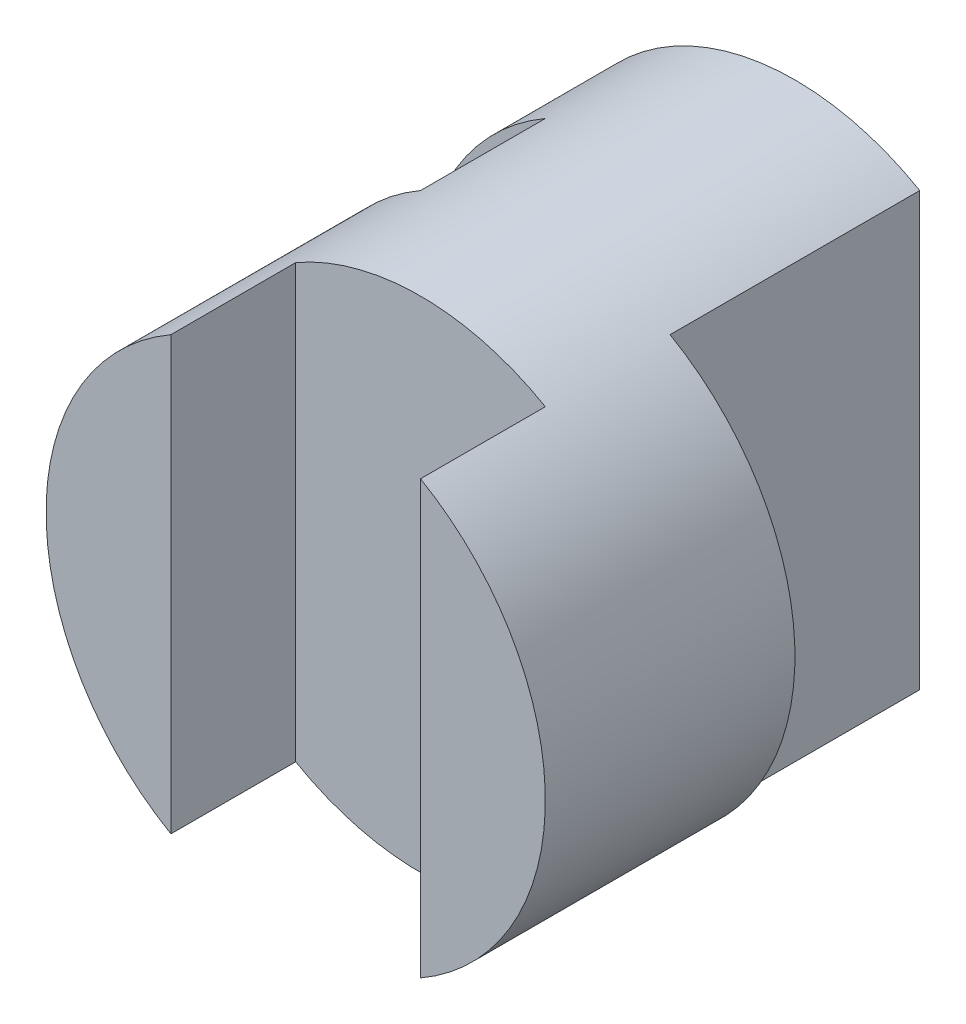
from build123d import *

# Parameters (mm, degrees)
SKETCH1_R           = 2
BOSS_EXTRUDE1_DEPTH = 4
SKETCH2_W           = 1
SKETCH2_H           = 1
SKETCH2_H_2         = 2
SKETCH2_W_2         = 2
CUT_EXTRUDE1_DEPTH  = 5


with BuildPart() as part:
    # Sketch1 → Boss-Extrude1 (new body)
    with BuildSketch(Plane.XY):
        Circle(SKETCH1_R)
    extrude(amount=BOSS_EXTRUDE1_DEPTH)

    # Sketch2 → Cut-Extrude1 (cut, symmetric)
    with BuildSketch(Plane(origin=(0, 0, 0), x_dir=(1, 0, 0), z_dir=(0, 1, 0))):
        with Locations((-1.5, -1.5)):
            Rectangle(SKETCH2_W, SKETCH2_H)
        with Locations((1.5, -1)):
            Rectangle(SKETCH2_W, SKETCH2_H_2)
        with Locations((0, -3.5)):
            Rectangle(SKETCH2_W_2, SKETCH2_H)
    extrude(amount=CUT_EXTRUDE1_DEPTH, both=True, mode=Mode.SUBTRACT)


solid = part.part
